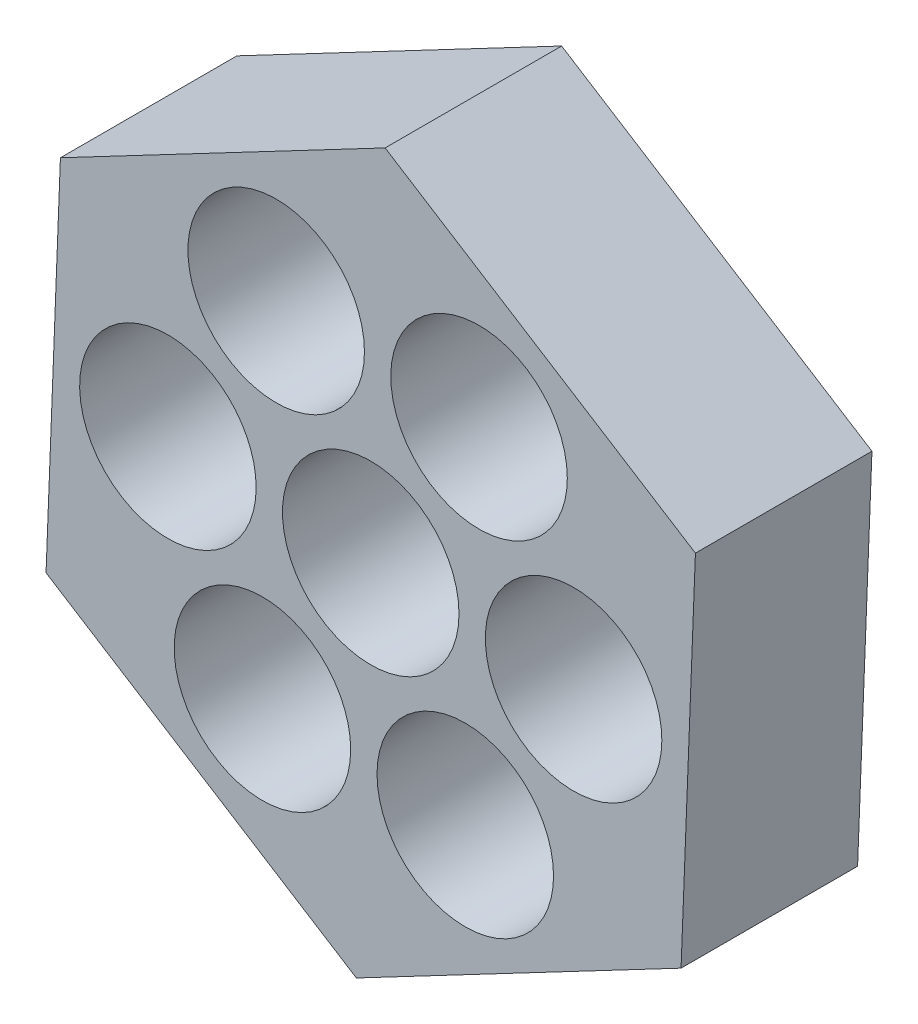
from build123d import *

# Parameters (mm, degrees)
SKETCH1_R           = 2.5
BOSS_EXTRUDE1_DEPTH = 5
SKETCH2_R           = 2.5
CUT_EXTRUDE1_DEPTH  = 9
CIRPATTERN1_COUNT   = 6


with BuildPart() as part:
    # Sketch1 → Boss-Extrude1 (new body)
    with BuildSketch(Plane.XY):
        Polygon((-8.789542733, 5.544721683), (-9.196641201, -4.839606453), (-0.407098468, -10.384328136), (8.789542733, -5.544721683), (9.196641201, 4.839606453), (0.407098468, 10.384328136), align=None)
        Circle(SKETCH1_R, mode=Mode.SUBTRACT)
    extrude(amount=BOSS_EXTRUDE1_DEPTH)

    # Sketch2 → Cut-Extrude1 (cut)
    with BuildSketch(Plane.XY.offset(5)):
        with Locations((-2.677725251, 5.08844647)):
            Circle(SKETCH2_R)
    cut_extrude1 = extrude(amount=-CUT_EXTRUDE1_DEPTH, mode=Mode.SUBTRACT)

    # CirPattern1: Cut-Extrude1 ×6 about axis
    cirpattern1_axis = Axis((0, 0, 0), (0, 0, 1))
    for i in range(1, CIRPATTERN1_COUNT):
        add(cut_extrude1.rotate(cirpattern1_axis, i * 360 / CIRPATTERN1_COUNT), mode=Mode.SUBTRACT)


solid = part.part
